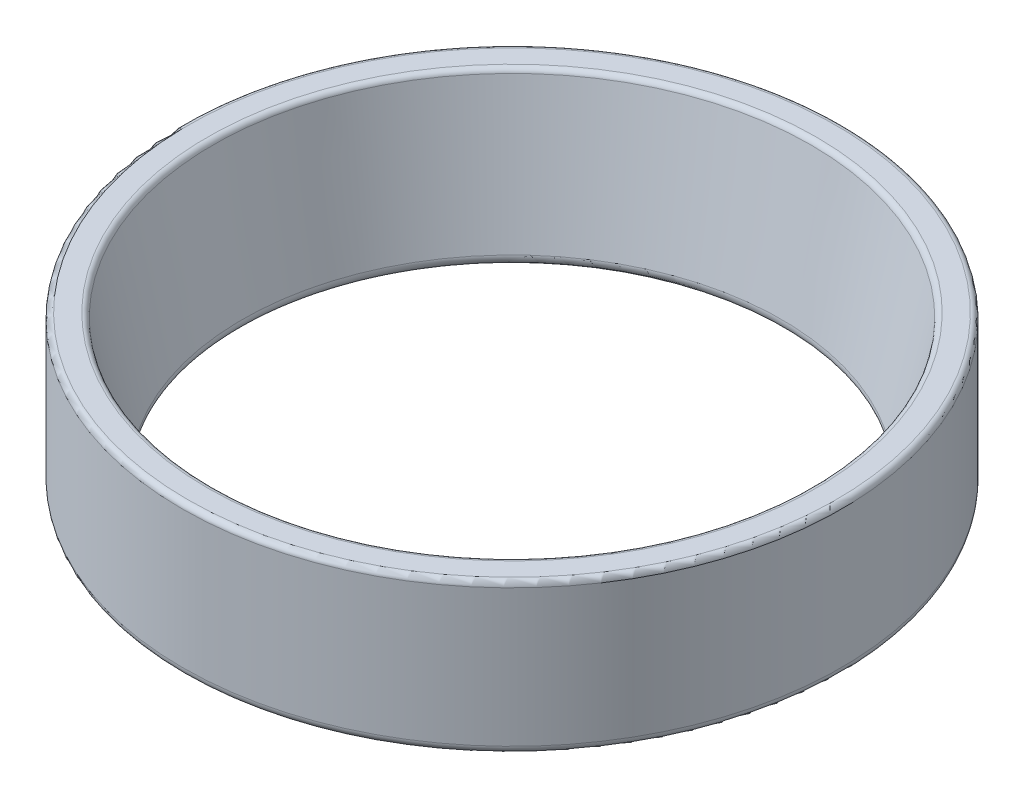
from build123d import *

# Parameters (mm, degrees)
FILLET1_R = 0.5
FILLET3_R = 0.8


with BuildPart() as part:
    # Sketch2 → Revolve1 (revolve)
    with BuildSketch(Plane.XY):
        Polygon((-30.5, 0), (-30.5, 14), (-27.75, 14), (-24.75, 0), align=None)
    revolve(axis=Axis((0, 0, 0), (0, 1, 0)))

    # Fillet1
    fillet1_edges = [part.edges().sort_by_distance(p)[0] for p in [
        (27.75, 14, 0),
        (30.5, 14, 0),
    ]]
    fillet(fillet1_edges, radius=FILLET1_R)

    # Fillet3
    fillet3_edges = [part.edges().sort_by_distance(p)[0] for p in [
        (30.5, 0, 0),
        (24.75, 0, 0),
    ]]
    fillet(fillet3_edges, radius=FILLET3_R)


solid = part.part
